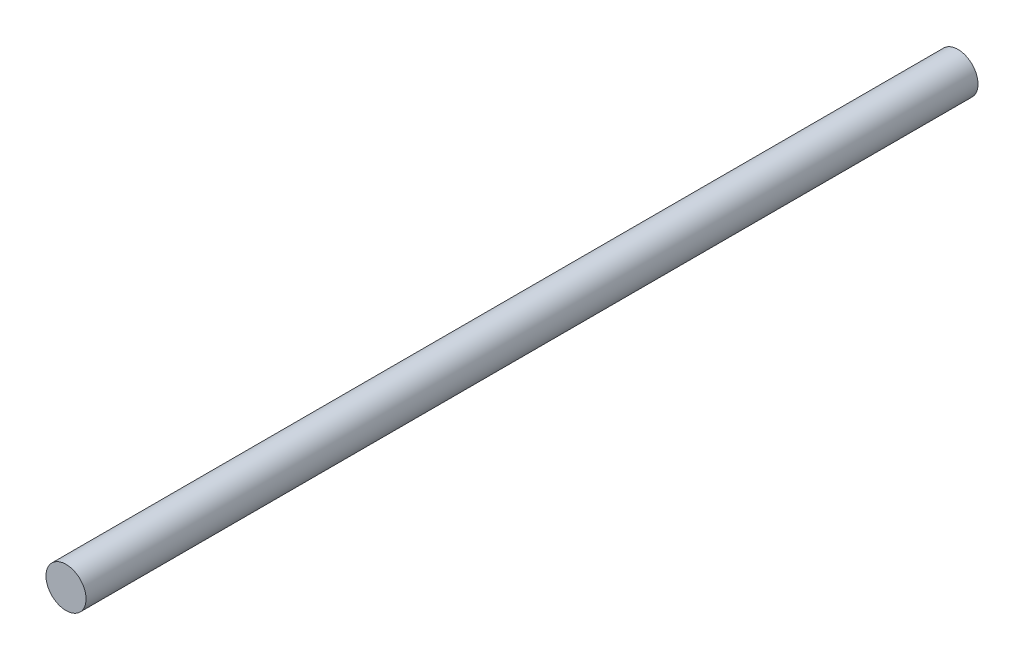
from build123d import *

# Parameters (mm, degrees)
SKETCH2_R           = 5
BOSS_EXTRUDE1_DEPTH = 222.4


with BuildPart() as part:
    # Sketch2 → Boss-Extrude1 (new body)
    with BuildSketch(Plane.XY):
        Circle(SKETCH2_R)
    extrude(amount=BOSS_EXTRUDE1_DEPTH)


solid = part.part
